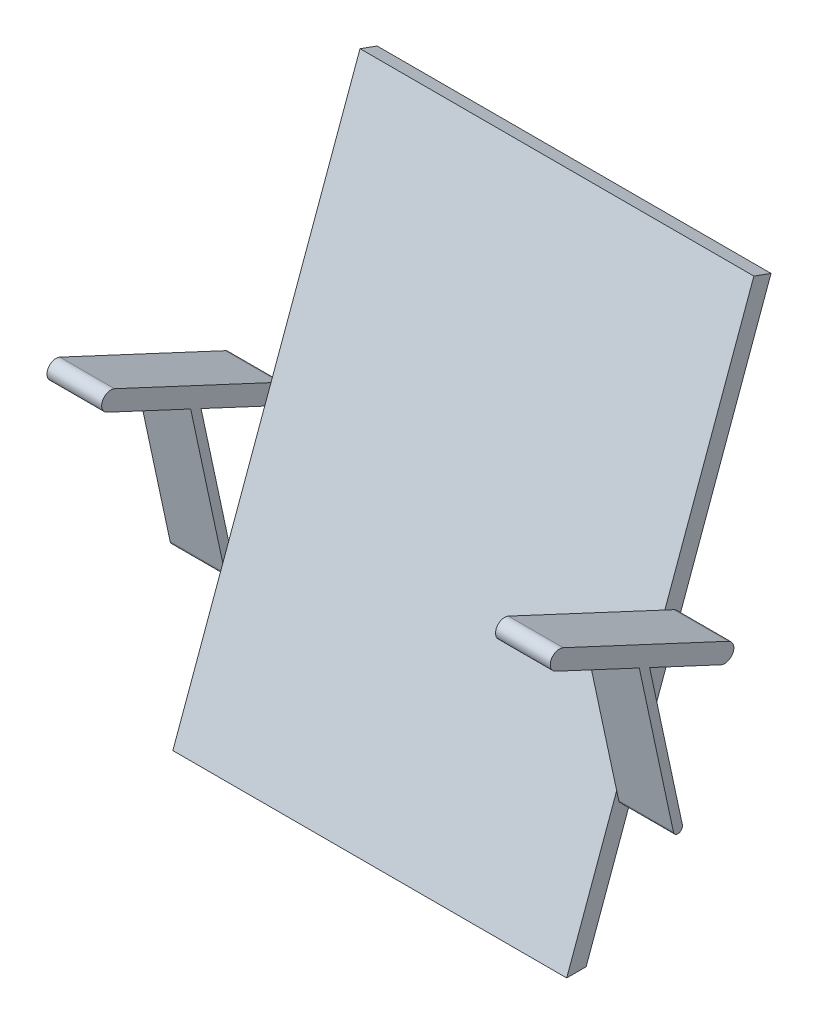
from build123d import *

# Parameters (mm, degrees)
BOSS_EXTRUDE1_DEPTH = 215.9
BOSS_EXTRUDE2_DEPTH = 60


with BuildPart() as part:
    # Sketch1 → Boss-Extrude1 (new, symmetric)
    with BuildSketch(Plane(origin=(0, 0, 0), x_dir=(0, 0, -1), z_dir=(1, 0, 0))):
        Polygon((0, 0), (-21.28355545, 0), (183.928530546, 563.815572472), (202.722382962, 556.975169605), align=None)
    extrude(amount=BOSS_EXTRUDE1_DEPTH, both=True)

    # Sketch2 → Boss-Extrude2 (add)
    with BuildSketch(Plane(origin=(215.9, 0, 0), x_dir=(0, 0, -1), z_dir=(1, 0, 0))):
        with BuildLine():
            Line((-1.717345436, 314.558459548), (9.648049621, 309.258688795))
            Line((9.648049621, 309.258688795), (6.222130729, 325.218973302))
            ThreePointArc((6.222130729, 325.218973302), (0.284125678, 329.058256569), (-3.55515759, 323.120251518))
            Line((-3.55515759, 323.120251518), (-1.717345436, 314.558459548))
        make_face()
        with BuildLine():
            Line((9.648049621, 309.258688795), (79.43330187, 276.717291245))
            Line((79.43330187, 276.717291245), (86.299833965, 295.582933124))
            Line((86.299833965, 295.582933124), (-85.071109517, 375.494516454))
            ThreePointArc((-85.071109517, 375.494516454), (-98.360370005, 370.657621201), (-93.523474752, 357.368360714))
            Line((-93.523474752, 357.368360714), (-1.717345436, 314.558459548))
            Line((-1.717345436, 314.558459548), (-3.55515759, 323.120251518))
            ThreePointArc((-3.55515759, 323.120251518), (0.284125678, 329.058256569), (6.222130729, 325.218973302))
            Line((6.222130729, 325.218973302), (9.648049621, 309.258688795))
        make_face()
        Polygon((39.930228547, 168.18348929), (9.648049621, 309.258688795), (-1.717345436, 314.558459548), (33.496662431, 150.507411661), align=None)
        with BuildLine():
            Line((45.549887934, 142.00325401), (39.930228547, 168.18348929))
            Line((39.930228547, 168.18348929), (33.496662431, 150.507411661))
            Line((33.496662431, 150.507411661), (35.772599615, 139.904532226))
            ThreePointArc((35.772599615, 139.904532226), (41.710604666, 136.065248958), (45.549887934, 142.00325401))
        make_face()
        with BuildLine():
            Line((79.43330187, 276.717291245), (87.738082656, 272.844708365))
            ThreePointArc((87.738082656, 272.844708365), (101.027343143, 277.681603618), (96.19044789, 290.970864106))
            Line((96.19044789, 290.970864106), (86.299833965, 295.582933124))
            Line((86.299833965, 295.582933124), (79.43330187, 276.717291245))
        make_face()
    boss_extrude2 = extrude(amount=BOSS_EXTRUDE2_DEPTH)

    # Mirror1: Boss-Extrude2 across plane
    add(boss_extrude2.mirror(Plane(origin=(0, 0, 0), x_dir=(0, 0, 1), z_dir=(1, 0, 0))))


solid = part.part
